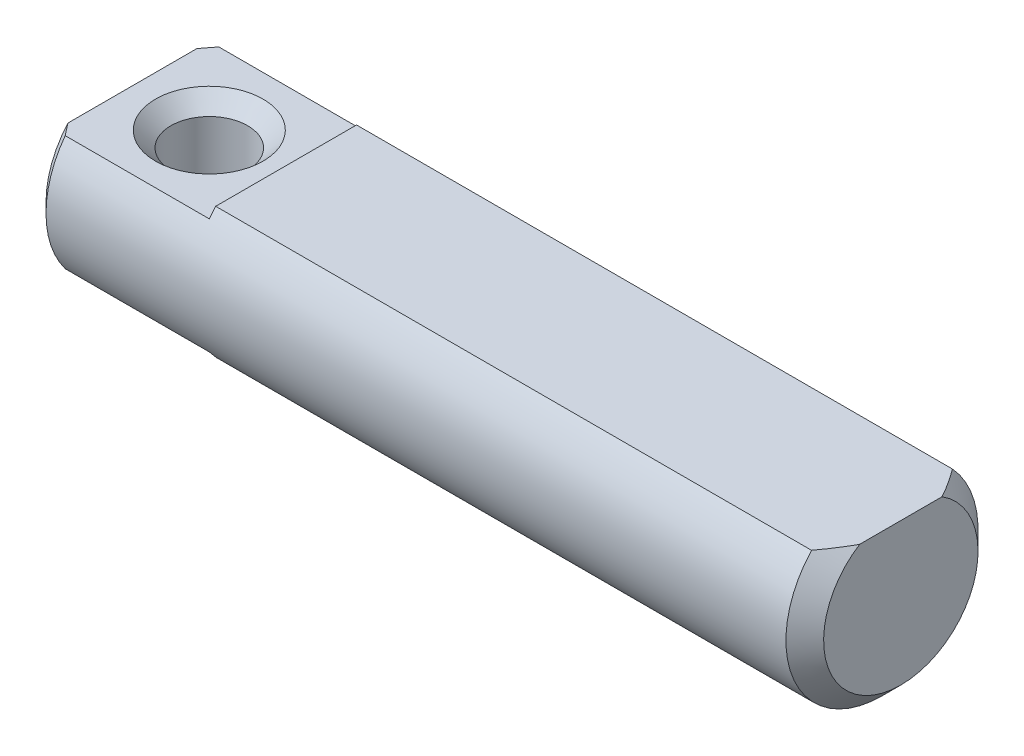
from build123d import *

# Parameters (mm, degrees)
SKETCH2_W               = 20
SKETCH2_H               = 3
CUT_EXTRUDE1_DEPTH      = 4
SKETCH3_W               = 20
SKETCH3_H               = 3
CUT_EXTRUDE2_DEPTH      = 4
SKETCH5_W               = 20
SKETCH5_H               = 0.8
CUT_EXTRUDE3_DEPTH      = 3.5
CUT_EXTRUDE3_DEPTH_BACK = 3.5


with BuildPart() as part:
    # Sketch1 → Revolve1 (revolve)
    with BuildSketch(Plane.XY):
        Polygon((0, 0), (0, 2.25), (0.25, 2.5), (19.5095, 2.5), (20, 2.0095), (20, 0), align=None)
    revolve(axis=Axis((20, 0, 0), (-1, 0, 0)))

    # Sketch2 → Cut-Extrude1 (cut)
    with BuildSketch(Plane(origin=(0, 0, 0), x_dir=(0, 0, -1), z_dir=(1, 0, 0))):
        with Locations((0, 3)):
            Rectangle(SKETCH2_W, SKETCH2_H)
    extrude(amount=CUT_EXTRUDE1_DEPTH, mode=Mode.SUBTRACT)

    # Sketch3 → Cut-Extrude2 (cut)
    with BuildSketch(Plane(origin=(0, 0, 0), x_dir=(0, 0, -1), z_dir=(1, 0, 0))):
        with Locations((0, -3)):
            Rectangle(SKETCH3_W, SKETCH3_H)
    extrude(amount=CUT_EXTRUDE2_DEPTH, mode=Mode.SUBTRACT)

    # Sketch4 → Cut-Revolve1 (revolve, cut)
    with BuildSketch(Plane.XY):
        Polygon((2, 1.5), (3.4, 1.5), (3, 1.1), (3, -1.1), (3.4, -1.5), (2, -1.5), align=None)
    revolve(axis=Axis((2, -1.5, 0), (0, 1, 0)), mode=Mode.SUBTRACT)

    # Sketch5 → Cut-Extrude3 (cut, two sides)
    with BuildSketch(Plane.XY) as cut_extrude3_sk:
        with Locations((10, 2.1)):
            Rectangle(SKETCH5_W, SKETCH5_H)
    extrude(amount=CUT_EXTRUDE3_DEPTH, mode=Mode.SUBTRACT)
    extrude(cut_extrude3_sk.sketch, amount=-CUT_EXTRUDE3_DEPTH_BACK, mode=Mode.SUBTRACT)


solid = part.part
